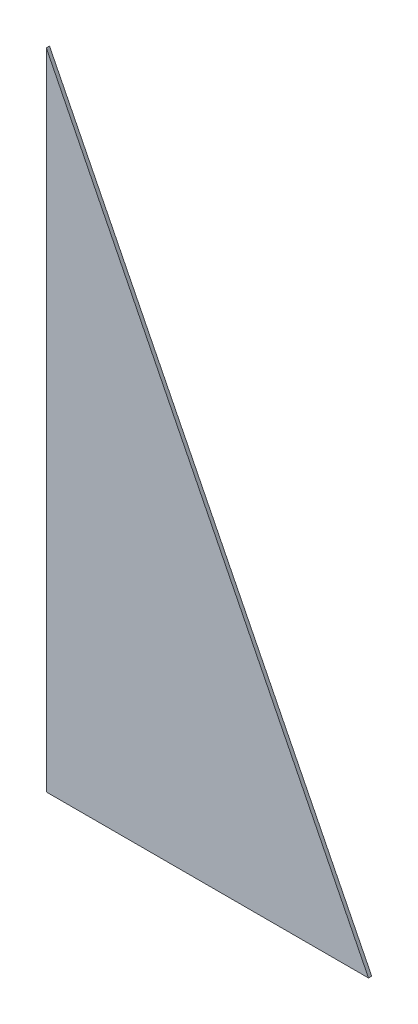
from build123d import *

# Parameters (mm, degrees)
BOSS_EXTRUDE2_DEPTH = 5


with BuildPart() as part:
    # Sketch2 → Boss-Extrude2 (new body, symmetric)
    with BuildSketch(Plane.XY):
        Polygon((0, 0), (1000, 0), (0, 2000), align=None)
    extrude(amount=BOSS_EXTRUDE2_DEPTH, both=True)


solid = part.part
